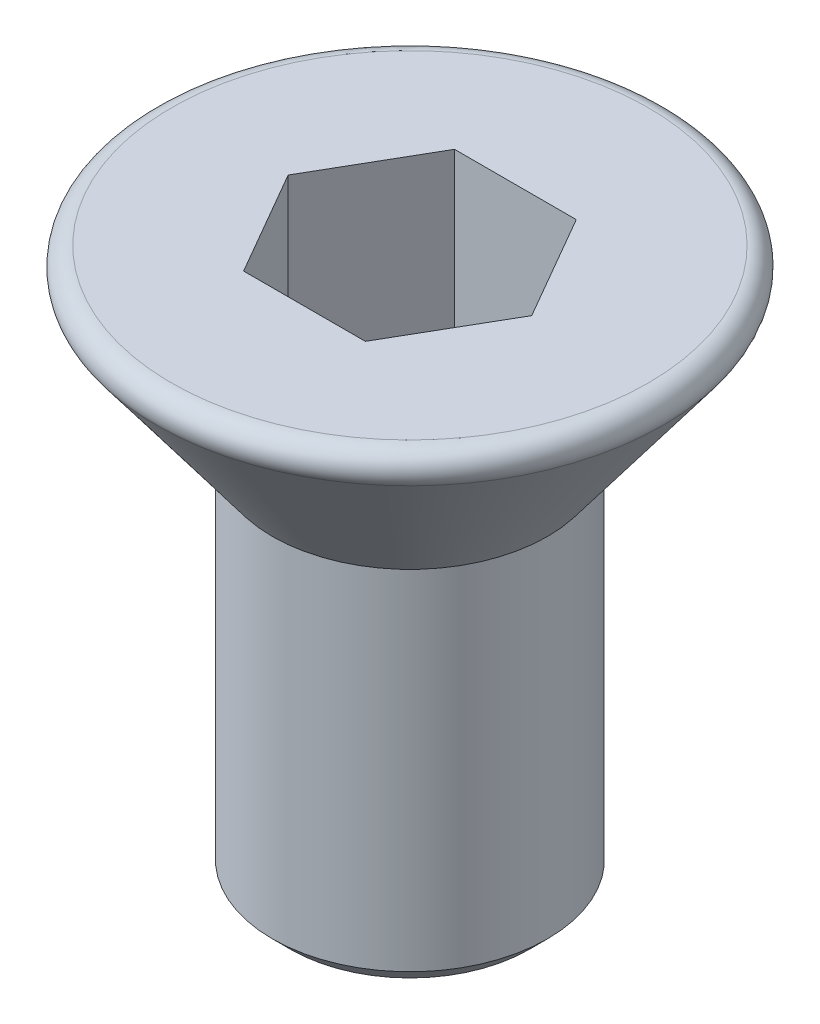
from build123d import *

# Parameters (mm, degrees)
SKETCH_2_R          = 1.5
EXTRUDE_1_DEPTH     = 4
CUT_EXTRUDE_1_DEPTH = 2
CHAMFER_1_SIZE      = 0.2
FILLET_1_R          = 0.2


with BuildPart() as part:
    # 草图1 → 旋转1 (revolve)
    with BuildSketch(Plane.XY):
        Polygon((0, 0), (0, -2), (1.5, -2), (3, 0), align=None)
    revolve(axis=Axis((0, 0, 0), (0, -1, 0)))

    # 草图2 → 凸台-拉伸1 (add)
    with BuildSketch(Plane.XZ.offset(2)):
        Circle(SKETCH_2_R)
    extrude(amount=EXTRUDE_1_DEPTH)

    # 草图3 → 切除-拉伸1 (cut)
    with BuildSketch(Plane(origin=(0, 0, 0), x_dir=(1, 0, 0), z_dir=(0, 1, 0))):
        Polygon((-1.327905619, 0), (-0.66395281, -1.15), (0.66395281, -1.15), (1.327905619, 0), (0.66395281, 1.15), (-0.66395281, 1.15), align=None)
    extrude(amount=-CUT_EXTRUDE_1_DEPTH, mode=Mode.SUBTRACT)

    # 倒角1
    chamfer_1_edges = [part.edges().sort_by_distance(p)[0] for p in [
        (-1.5, -6, 0),
    ]]
    chamfer(chamfer_1_edges, length=CHAMFER_1_SIZE)

    # 圆角1
    fillet_1_edges = [part.edges().sort_by_distance(p)[0] for p in [
        (-3, 0, 0),
    ]]
    fillet(fillet_1_edges, radius=FILLET_1_R)


solid = part.part
